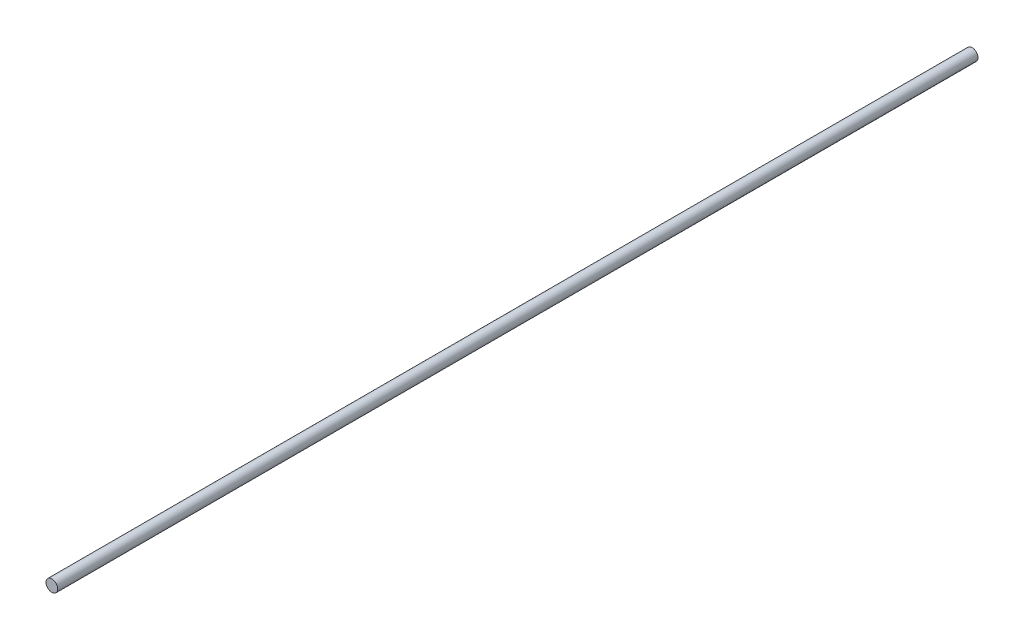
from build123d import *

# Parameters (mm, degrees)
ESQUISSE1_R        = 4
BOSS_EXTRU_1_DEPTH = 628


with BuildPart() as part:
    # Esquisse1 → Boss.-Extru.1 (new body)
    with BuildSketch(Plane.XY):
        Circle(ESQUISSE1_R)
    extrude(amount=BOSS_EXTRU_1_DEPTH)


solid = part.part
